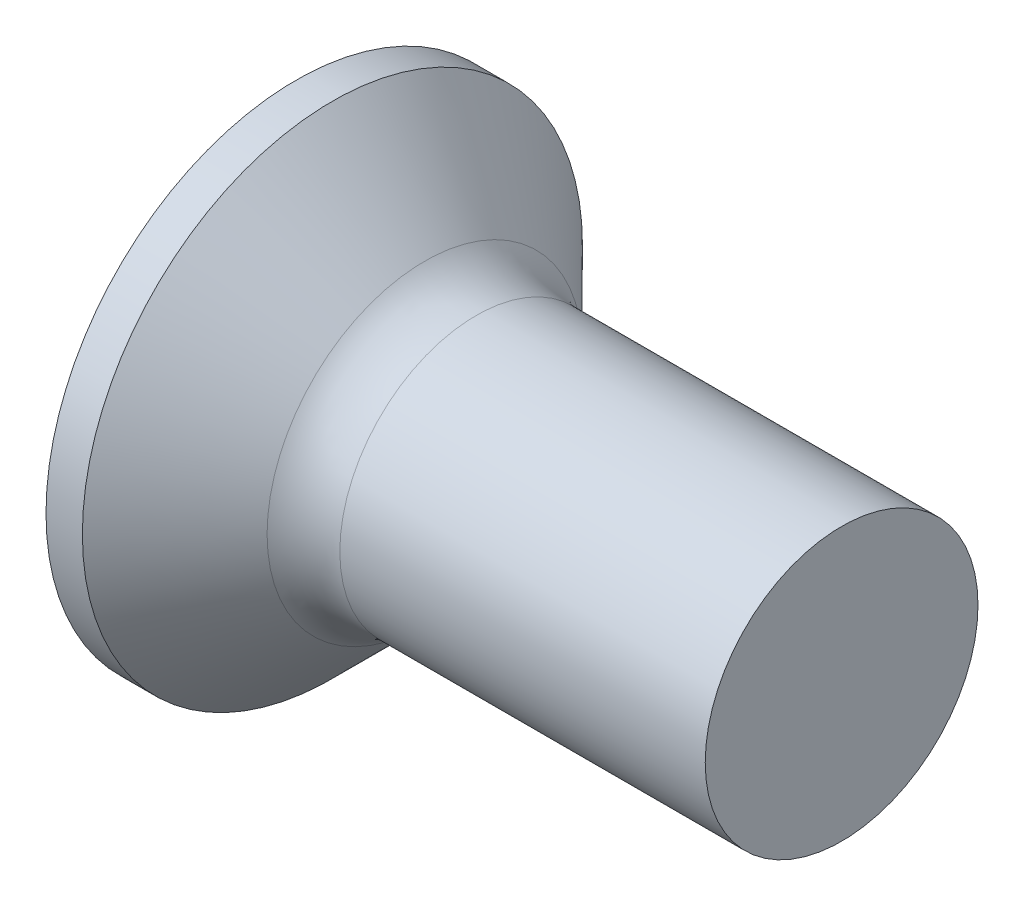
from build123d import *

# Parameters (mm, degrees)
FILLET1_R    = 0.8
SKETCH3_W    = 0.74
SKETCH3_H    = 3
SKETCH4_W    = 0.74
SKETCH4_H    = 0.995702004
RECPAT_COUNT = 2
RECPAT_ANGLE = 90


with BuildPart() as part:
    # BodySke → Base-Revolve (revolve)
    with BuildSketch(Plane.XY, mode=Mode.PRIVATE) as base_revolve_sk:
        Polygon((0, 0), (0, 2.75), (0.4, 2.75), (1.65, 1.5), (6, 1.5), (6, 0), align=None)
    revolve(base_revolve_sk.sketch.rotate(Axis((-6.35, 0, 0), (1, 0, 0)), 90), axis=Axis((-6.35, 0, 0), (1, 0, 0)))  # turned: the seam where the file's is

    # Fillet1
    fillet1_edges = [part.edges().sort_by_distance(p)[0] for p in [
        (1.65, 0, -1.5),
    ]]
    fillet(fillet1_edges, radius=FILLET1_R)

    # Sketch3 → Recess section 0
    with BuildSketch(Plane.ZY):
        Rectangle(SKETCH3_W, SKETCH3_H)
    # Sketch4 → Recess section 1
    with BuildSketch(Plane.ZY.offset(-2.01)):
        Rectangle(SKETCH4_W, SKETCH4_H)
    recess = loft(mode=Mode.SUBTRACT)

    # RecPat: Recess ×2 about axis
    recpat_axis = Axis((0, 0, 0), (1, 0, 0))
    for i in range(1, RECPAT_COUNT):
        add(recess.rotate(recpat_axis, i * RECPAT_ANGLE / (RECPAT_COUNT - 1)), mode=Mode.SUBTRACT)

    # RecCorSke → RecessCore (revolve, cut)
    with BuildSketch(Plane.XY, mode=Mode.PRIVATE) as recesscore_sk:
        Polygon((0, 0), (0, 0.696552892), (2.01, 0.556), (2.190655351, 0), align=None)
    revolve(recesscore_sk.sketch.rotate(Axis((-3.175, 0, 0), (1, 0, 0)), 90), axis=Axis((-3.175, 0, 0), (1, 0, 0)), mode=Mode.SUBTRACT)  # turned: the seam where the file's is


solid = part.part
